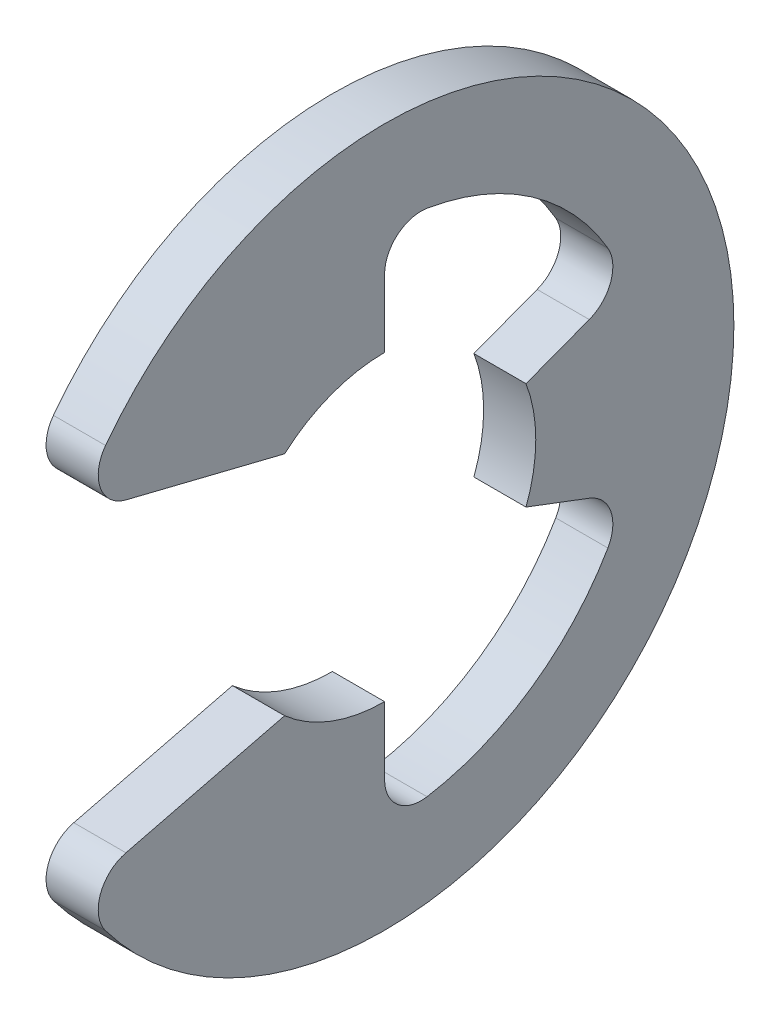
from build123d import *

# Parameters (mm, degrees)
EXTRUDE1_DEPTH = 0.3175
FILLET1_R      = 0.4445


with BuildPart() as part:
    # Sketch1 → Extrude1 (new body, symmetric)
    with BuildSketch(Plane(origin=(0, 0, 0), x_dir=(0, 0, -1), z_dir=(1, 0, 0))):
        with BuildLine():
            Line((-3.749912818, -2.009707469), (-1.21803776, -1.381125))
            ThreePointArc((-1.21803776, -1.381125), (-0.651068569, -1.722565519), (0, -1.8415))
            Line((0, -1.8415), (0, -3.146322581))
            ThreePointArc((0, -3.146322581), (1.78877032, -2.58836754), (2.943115281, -1.112393016))
            Line((2.943115281, -1.112393016), (1.722565519, -0.651068569))
            ThreePointArc((1.722565519, -0.651068569), (1.8415, 0), (1.722565519, 0.651068569))
            Line((1.722565519, 0.651068569), (2.943115281, 1.112393016))
            ThreePointArc((2.943115281, 1.112393016), (1.78877032, 2.58836754), (0, 3.146322581))
            Line((0, 3.146322581), (0, 1.8415))
            ThreePointArc((0, 1.8415), (-0.651068569, 1.722565519), (-1.21803776, 1.381125))
            Line((-1.21803776, 1.381125), (-3.749912818, 2.009707469))
            ThreePointArc((-3.749912818, 2.009707469), (4.2545, 0), (-3.749912818, -2.009707469))
        make_face()
    extrude(amount=EXTRUDE1_DEPTH, both=True)

    # Fillet1
    fillet1_edges = [part.edges().sort_by_distance(p)[0] for p in [
        (0, -2.009707469, 3.749912818),
        (0, -3.146322581, 0),
        (0, -1.112393016, -2.943115281),
        (0, 1.112393016, -2.943115281),
        (0, 3.146322581, 0),
        (0, 2.009707469, 3.749912818),
    ]]
    fillet(fillet1_edges, radius=FILLET1_R)


solid = part.part
